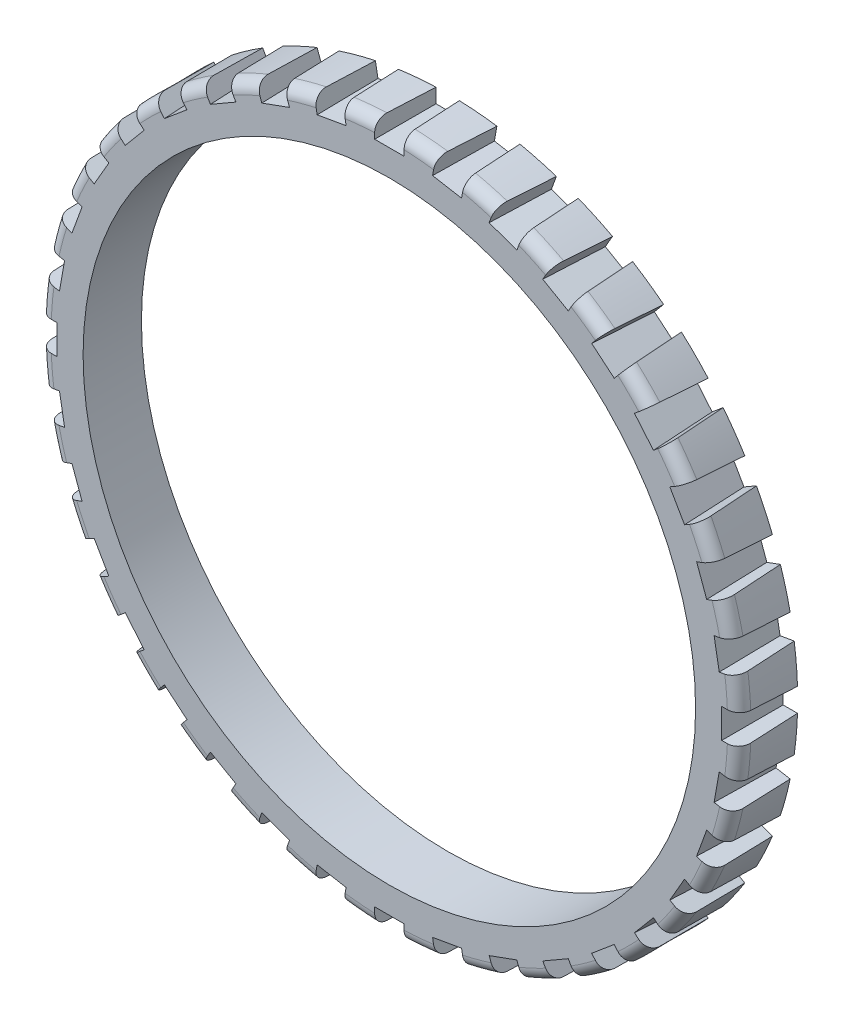
from build123d import *

# Parameters (mm, degrees)
SKETCH3_R                 = 76.2
SKETCH3_R_2               = 66.675
BOSS_EXTRUDE2_DEPTH       = 12.7
FILLET2_R                 = 2.54
CUT_EXTRUDE4_DEPTH        = 18.034
CUT_EXTRUDE4_DRAFT        = -3
CIRPATTERN1_COPY_1_DEPTH  = 18.034
CIRPATTERN1_COPY_1_DRAFT  = -3
CIRPATTERN1_COPY_2_DEPTH  = 18.034
CIRPATTERN1_COPY_2_DRAFT  = -3
CIRPATTERN1_COPY_3_DEPTH  = 18.034
CIRPATTERN1_COPY_3_DRAFT  = -3
CIRPATTERN1_COPY_4_DEPTH  = 18.034
CIRPATTERN1_COPY_4_DRAFT  = -3
CIRPATTERN1_COPY_5_DEPTH  = 18.034
CIRPATTERN1_COPY_5_DRAFT  = -3
CIRPATTERN1_COPY_6_DEPTH  = 18.034
CIRPATTERN1_COPY_6_DRAFT  = -3
CIRPATTERN1_COPY_7_DEPTH  = 18.034
CIRPATTERN1_COPY_7_DRAFT  = -3
CIRPATTERN1_COPY_8_DEPTH  = 18.034
CIRPATTERN1_COPY_8_DRAFT  = -3
CIRPATTERN1_COPY_9_DEPTH  = 18.034
CIRPATTERN1_COPY_9_DRAFT  = -3
CIRPATTERN1_COPY_10_DEPTH = 18.034
CIRPATTERN1_COPY_10_DRAFT = -3
CIRPATTERN1_COPY_11_DEPTH = 18.034
CIRPATTERN1_COPY_11_DRAFT = -3
CIRPATTERN1_COPY_12_DEPTH = 18.034
CIRPATTERN1_COPY_12_DRAFT = -3
CIRPATTERN1_COPY_13_DEPTH = 18.034
CIRPATTERN1_COPY_13_DRAFT = -3
CIRPATTERN1_COPY_14_DEPTH = 18.034
CIRPATTERN1_COPY_14_DRAFT = -3
CIRPATTERN1_COPY_15_DEPTH = 18.034
CIRPATTERN1_COPY_15_DRAFT = -3
CIRPATTERN1_COPY_16_DEPTH = 18.034
CIRPATTERN1_COPY_16_DRAFT = -3
CIRPATTERN1_COPY_17_DEPTH = 18.034
CIRPATTERN1_COPY_17_DRAFT = -3
CIRPATTERN1_COPY_18_DEPTH = 18.034
CIRPATTERN1_COPY_18_DRAFT = -3
CIRPATTERN1_COPY_19_DEPTH = 18.034
CIRPATTERN1_COPY_19_DRAFT = -3
CIRPATTERN1_COPY_20_DEPTH = 18.034
CIRPATTERN1_COPY_20_DRAFT = -3
CIRPATTERN1_COPY_21_DEPTH = 18.034
CIRPATTERN1_COPY_21_DRAFT = -3
CIRPATTERN1_COPY_22_DEPTH = 18.034
CIRPATTERN1_COPY_22_DRAFT = -3
CIRPATTERN1_COPY_23_DEPTH = 18.034
CIRPATTERN1_COPY_23_DRAFT = -3
CIRPATTERN1_COPY_24_DEPTH = 18.034
CIRPATTERN1_COPY_24_DRAFT = -3
CIRPATTERN1_COPY_25_DEPTH = 18.034
CIRPATTERN1_COPY_25_DRAFT = -3
CIRPATTERN1_COPY_26_DEPTH = 18.034
CIRPATTERN1_COPY_26_DRAFT = -3
CIRPATTERN1_COPY_27_DEPTH = 18.034
CIRPATTERN1_COPY_27_DRAFT = -3
CIRPATTERN1_COPY_28_DEPTH = 18.034
CIRPATTERN1_COPY_28_DRAFT = -3
CIRPATTERN1_COPY_29_DEPTH = 18.034
CIRPATTERN1_COPY_29_DRAFT = -3
CIRPATTERN1_COPY_30_DEPTH = 18.034
CIRPATTERN1_COPY_30_DRAFT = -3
CIRPATTERN1_COPY_31_DEPTH = 18.034
CIRPATTERN1_COPY_31_DRAFT = -3
CIRPATTERN1_COPY_32_DEPTH = 18.034
CIRPATTERN1_COPY_32_DRAFT = -3
CIRPATTERN1_COPY_33_DEPTH = 18.034
CIRPATTERN1_COPY_33_DRAFT = -3
CIRPATTERN1_COPY_34_DEPTH = 18.034
CIRPATTERN1_COPY_34_DRAFT = -3
CIRPATTERN1_COPY_35_DEPTH = 18.034
CIRPATTERN1_COPY_35_DRAFT = -3


with BuildPart() as part:
    # Sketch3 → Boss-Extrude2 (new body)
    with BuildSketch(Plane.XY.offset(12.7)):
        Circle(SKETCH3_R)
        Circle(SKETCH3_R_2, mode=Mode.SUBTRACT)
    extrude(amount=BOSS_EXTRUDE2_DEPTH)

    # Fillet2
    fillet2_edges = [part.edges().sort_by_distance(p)[0] for p in [
        (-76.2, 0, 25.4),
    ]]
    fillet(fillet2_edges, radius=FILLET2_R)


with BuildPart() as cut_extrude4_tool:
    # Sketch5 → Cut-Extrude4 (with draft: the straight prism first)
    with BuildSketch(Plane.XY.offset(12.7)):
        with BuildLine():
            Line((10.723226296, 75.441715369), (10.179246481, 72.356652535))
            Line((10.179246481, 72.356652535), (15.182069867, 71.474519792))
            Line((15.182069867, 71.474519792), (15.726049682, 74.559582626))
            ThreePointArc((15.726049682, 74.559582626), (13.231991138, 75.04235078), (10.723226296, 75.441715369))
        make_face()
    extrude(amount=CUT_EXTRUDE4_DEPTH)
    # Cut-Extrude4: the draft: its side faces are tilted about the plane it starts from
    cut_extrude4_sides = [cut_extrude4_tool.faces().sort_by_distance(p)[0] for p in [
        (10.451236389, 73.899183952, 21.717),
        (12.680658174, 71.915586164, 21.717),
        (15.454059774, 73.017051209, 21.717),
        (13.231991138, 75.04235078, 21.717),
    ]]
    draft(cut_extrude4_sides, Plane.XY.offset(12.7), CUT_EXTRUDE4_DRAFT)


with BuildPart() as part_1:
    add(part.part)

    # Cut-Extrude4: cut by cut_extrude4_tool
    add(cut_extrude4_tool.part, mode=Mode.SUBTRACT)


with BuildPart() as cirpattern1_copy_1_tool:
    # CirPattern1 copy 1 sketch → CirPattern1 copy 1 (with draft: the straight prism first)
    with BuildSketch(Plane(origin=(0, 0, 12.7), x_dir=(0.984807753012208, -0.17364817766693033, 0), z_dir=(0, 0, 1))):
        with BuildLine():
            Line((10.723226296, 75.441715369), (10.179246481, 72.356652535))
            Line((10.179246481, 72.356652535), (15.182069867, 71.474519792))
            Line((15.182069867, 71.474519792), (15.726049682, 74.559582626))
            ThreePointArc((15.726049682, 74.559582626), (13.231991138, 75.04235078), (10.723226296, 75.441715369))
        make_face()
    extrude(amount=CIRPATTERN1_COPY_1_DEPTH)
    # CirPattern1 copy 1: the draft: its side faces are tilted about the plane it starts from
    cirpattern1_copy_1_sides = [cirpattern1_copy_1_tool.faces().sort_by_distance(p)[0] for p in [
        (23.124917249, 70.961651144, 21.717),
        (24.976020966, 68.621053633, 21.717),
        (27.898555762, 69.224188815, 21.717),
        (26.061934921, 71.604577704, 21.717),
    ]]
    draft(cirpattern1_copy_1_sides, Plane(origin=(0, 0, 12.7), x_dir=(0.984807753012208, -0.17364817766693033, 0), z_dir=(0, 0, 1)), CIRPATTERN1_COPY_1_DRAFT)


with BuildPart() as part_2:
    add(part_1.part)

    # CirPattern1 copy 1: cut by cirpattern1_copy_1_tool
    add(cirpattern1_copy_1_tool.part, mode=Mode.SUBTRACT)


with BuildPart() as cirpattern1_copy_2_tool:
    # CirPattern1 copy 2 sketch → CirPattern1 copy 2 (with draft: the straight prism first)
    with BuildSketch(Plane(origin=(0, 0, 12.7), x_dir=(0.9396926207859084, -0.3420201433256687, 0), z_dir=(0, 0, 1))):
        with BuildLine():
            Line((10.723226296, 75.441715369), (10.179246481, 72.356652535))
            Line((10.179246481, 72.356652535), (15.182069867, 71.474519792))
            Line((15.182069867, 71.474519792), (15.726049682, 74.559582626))
            ThreePointArc((15.726049682, 74.559582626), (13.231991138, 75.04235078), (10.723226296, 75.441715369))
        make_face()
    extrude(amount=CIRPATTERN1_COPY_2_DEPTH)
    # CirPattern1 copy 2: the draft: its side faces are tilted about the plane it starts from
    cirpattern1_copy_2_sides = [cirpattern1_copy_2_tool.faces().sort_by_distance(p)[0] for p in [
        (35.0959592, 65.867984474, 21.717),
        (36.5125, 63.241505112, 21.717),
        (39.495368251, 63.327984474, 21.717),
        (38.1, 65.991135769, 21.717),
    ]]
    draft(cirpattern1_copy_2_sides, Plane(origin=(0, 0, 12.7), x_dir=(0.9396926207859084, -0.3420201433256687, 0), z_dir=(0, 0, 1)), CIRPATTERN1_COPY_2_DRAFT)


with BuildPart() as part_3:
    add(part_2.part)

    # CirPattern1 copy 2: cut by cirpattern1_copy_2_tool
    add(cirpattern1_copy_2_tool.part, mode=Mode.SUBTRACT)


with BuildPart() as cirpattern1_copy_3_tool:
    # CirPattern1 copy 3 sketch → CirPattern1 copy 3 (with draft: the straight prism first)
    with BuildSketch(Plane(origin=(0, 0, 12.7), x_dir=(0.8660254037844387, -0.49999999999999994, 0), z_dir=(0, 0, 1))):
        with BuildLine():
            Line((10.723226296, 75.441715369), (10.179246481, 72.356652535))
            Line((10.179246481, 72.356652535), (15.182069867, 71.474519792))
            Line((15.182069867, 71.474519792), (15.726049682, 74.559582626))
            ThreePointArc((15.726049682, 74.559582626), (13.231991138, 75.04235078), (10.723226296, 75.441715369))
        make_face()
    extrude(amount=CIRPATTERN1_COPY_3_DEPTH)
    # CirPattern1 copy 3: the draft: its side faces are tilted about the plane it starts from
    cirpattern1_copy_3_sides = [cirpattern1_copy_3_tool.faces().sort_by_distance(p)[0] for p in [
        (46.00062819, 58.772952427, 21.717),
        (46.939565197, 55.940395459, 21.717),
        (49.89213396, 55.507591369, 21.717),
        (48.980415858, 58.372586566, 21.717),
    ]]
    draft(cirpattern1_copy_3_sides, Plane(origin=(0, 0, 12.7), x_dir=(0.8660254037844387, -0.49999999999999994, 0), z_dir=(0, 0, 1)), CIRPATTERN1_COPY_3_DRAFT)


with BuildPart() as part_4:
    add(part_3.part)

    # CirPattern1 copy 3: cut by cirpattern1_copy_3_tool
    add(cirpattern1_copy_3_tool.part, mode=Mode.SUBTRACT)


with BuildPart() as cirpattern1_copy_4_tool:
    # CirPattern1 copy 4 sketch → CirPattern1 copy 4 (with draft: the straight prism first)
    with BuildSketch(Plane(origin=(0, 0, 12.7), x_dir=(0.766044443118978, -0.6427876096865393, 0), z_dir=(0, 0, 1))):
        with BuildLine():
            Line((10.723226296, 75.441715369), (10.179246481, 72.356652535))
            Line((10.179246481, 72.356652535), (15.182069867, 71.474519792))
            Line((15.182069867, 71.474519792), (15.726049682, 74.559582626))
            ThreePointArc((15.726049682, 74.559582626), (13.231991138, 75.04235078), (10.723226296, 75.441715369))
        make_face()
    extrude(amount=CIRPATTERN1_COPY_4_DEPTH)
    # CirPattern1 copy 4: the draft: its side faces are tilted about the plane it starts from
    cirpattern1_copy_4_sides = [cirpattern1_copy_4_tool.faces().sort_by_distance(p)[0] for p in [
        (55.50759137, 49.892133961, 21.717),
        (55.940395459, 46.939565198, 21.717),
        (58.772952426, 46.00062819, 21.717),
        (58.372586566, 48.980415859, 21.717),
    ]]
    draft(cirpattern1_copy_4_sides, Plane(origin=(0, 0, 12.7), x_dir=(0.766044443118978, -0.6427876096865393, 0), z_dir=(0, 0, 1)), CIRPATTERN1_COPY_4_DRAFT)


with BuildPart() as part_5:
    add(part_4.part)

    # CirPattern1 copy 4: cut by cirpattern1_copy_4_tool
    add(cirpattern1_copy_4_tool.part, mode=Mode.SUBTRACT)


with BuildPart() as cirpattern1_copy_5_tool:
    # CirPattern1 copy 5 sketch → CirPattern1 copy 5 (with draft: the straight prism first)
    with BuildSketch(Plane(origin=(0, 0, 12.7), x_dir=(0.6427876096865394, -0.766044443118978, 0), z_dir=(0, 0, 1))):
        with BuildLine():
            Line((10.723226296, 75.441715369), (10.179246481, 72.356652535))
            Line((10.179246481, 72.356652535), (15.182069867, 71.474519792))
            Line((15.182069867, 71.474519792), (15.726049682, 74.559582626))
            ThreePointArc((15.726049682, 74.559582626), (13.231991138, 75.04235078), (10.723226296, 75.441715369))
        make_face()
    extrude(amount=CIRPATTERN1_COPY_5_DEPTH)
    # CirPattern1 copy 5: the draft: its side faces are tilted about the plane it starts from
    cirpattern1_copy_5_sides = [cirpattern1_copy_5_tool.faces().sort_by_distance(p)[0] for p in [
        (63.327984474, 39.495368251, 21.717),
        (63.241505111, 36.5125, 21.717),
        (65.867984474, 35.095959199, 21.717),
        (65.991135769, 38.1, 21.717),
    ]]
    draft(cirpattern1_copy_5_sides, Plane(origin=(0, 0, 12.7), x_dir=(0.6427876096865394, -0.766044443118978, 0), z_dir=(0, 0, 1)), CIRPATTERN1_COPY_5_DRAFT)


with BuildPart() as part_6:
    add(part_5.part)

    # CirPattern1 copy 5: cut by cirpattern1_copy_5_tool
    add(cirpattern1_copy_5_tool.part, mode=Mode.SUBTRACT)


with BuildPart() as cirpattern1_copy_6_tool:
    # CirPattern1 copy 6 sketch → CirPattern1 copy 6 (with draft: the straight prism first)
    with BuildSketch(Plane(origin=(0, 0, 12.7), x_dir=(0.5000000000000001, -0.8660254037844386, 0), z_dir=(0, 0, 1))):
        with BuildLine():
            Line((10.723226296, 75.441715369), (10.179246481, 72.356652535))
            Line((10.179246481, 72.356652535), (15.182069867, 71.474519792))
            Line((15.182069867, 71.474519792), (15.726049682, 74.559582626))
            ThreePointArc((15.726049682, 74.559582626), (13.231991138, 75.04235078), (10.723226296, 75.441715369))
        make_face()
    extrude(amount=CIRPATTERN1_COPY_6_DEPTH)
    # CirPattern1 copy 6: the draft: its side faces are tilted about the plane it starts from
    cirpattern1_copy_6_sides = [cirpattern1_copy_6_tool.faces().sort_by_distance(p)[0] for p in [
        (69.224188816, 27.898555762, 21.717),
        (68.621053633, 24.976020967, 21.717),
        (70.961651143, 23.124917249, 21.717),
        (71.604577704, 26.061934922, 21.717),
    ]]
    draft(cirpattern1_copy_6_sides, Plane(origin=(0, 0, 12.7), x_dir=(0.5000000000000001, -0.8660254037844386, 0), z_dir=(0, 0, 1)), CIRPATTERN1_COPY_6_DRAFT)


with BuildPart() as part_7:
    add(part_6.part)

    # CirPattern1 copy 6: cut by cirpattern1_copy_6_tool
    add(cirpattern1_copy_6_tool.part, mode=Mode.SUBTRACT)


with BuildPart() as cirpattern1_copy_7_tool:
    # CirPattern1 copy 7 sketch → CirPattern1 copy 7 (with draft: the straight prism first)
    with BuildSketch(Plane(origin=(0, 0, 12.7), x_dir=(0.3420201433256688, -0.9396926207859083, 0), z_dir=(0, 0, 1))):
        with BuildLine():
            Line((10.723226296, 75.441715369), (10.179246481, 72.356652535))
            Line((10.179246481, 72.356652535), (15.182069867, 71.474519792))
            Line((15.182069867, 71.474519792), (15.726049682, 74.559582626))
            ThreePointArc((15.726049682, 74.559582626), (13.231991138, 75.04235078), (10.723226296, 75.441715369))
        make_face()
    extrude(amount=CIRPATTERN1_COPY_7_DEPTH)
    # CirPattern1 copy 7: the draft: its side faces are tilted about the plane it starts from
    cirpattern1_copy_7_sides = [cirpattern1_copy_7_tool.faces().sort_by_distance(p)[0] for p in [
        (73.017051209, 15.454059774, 21.717),
        (71.915586164, 12.680658174, 21.717),
        (73.899183952, 10.451236389, 21.717),
        (75.04235078, 13.231991139, 21.717),
    ]]
    draft(cirpattern1_copy_7_sides, Plane(origin=(0, 0, 12.7), x_dir=(0.3420201433256688, -0.9396926207859083, 0), z_dir=(0, 0, 1)), CIRPATTERN1_COPY_7_DRAFT)


with BuildPart() as part_8:
    add(part_7.part)

    # CirPattern1 copy 7: cut by cirpattern1_copy_7_tool
    add(cirpattern1_copy_7_tool.part, mode=Mode.SUBTRACT)


with BuildPart() as cirpattern1_copy_8_tool:
    # CirPattern1 copy 8 sketch → CirPattern1 copy 8 (with draft: the straight prism first)
    with BuildSketch(Plane(origin=(0, 0, 12.7), x_dir=(0.17364817766693041, -0.984807753012208, 0), z_dir=(0, 0, 1))):
        with BuildLine():
            Line((10.723226296, 75.441715369), (10.179246481, 72.356652535))
            Line((10.179246481, 72.356652535), (15.182069867, 71.474519792))
            Line((15.182069867, 71.474519792), (15.726049682, 74.559582626))
            ThreePointArc((15.726049682, 74.559582626), (13.231991138, 75.04235078), (10.723226296, 75.441715369))
        make_face()
    extrude(amount=CIRPATTERN1_COPY_8_DEPTH)
    # CirPattern1 copy 8: the draft: its side faces are tilted about the plane it starts from
    cirpattern1_copy_8_sides = [cirpattern1_copy_8_tool.faces().sort_by_distance(p)[0] for p in [
        (74.591327451, 2.54, 21.717),
        (73.025, 0, 21.717),
        (74.59132745, -2.54, 21.717),
        (76.2, 0, 21.717),
    ]]
    draft(cirpattern1_copy_8_sides, Plane(origin=(0, 0, 12.7), x_dir=(0.17364817766693041, -0.984807753012208, 0), z_dir=(0, 0, 1)), CIRPATTERN1_COPY_8_DRAFT)


with BuildPart() as part_9:
    add(part_8.part)

    # CirPattern1 copy 8: cut by cirpattern1_copy_8_tool
    add(cirpattern1_copy_8_tool.part, mode=Mode.SUBTRACT)


with BuildPart() as cirpattern1_copy_9_tool:
    # CirPattern1 copy 9 sketch → CirPattern1 copy 9 (with draft: the straight prism first)
    with BuildSketch(Plane(origin=(0, 0, 12.7), x_dir=(0, -1, 0), z_dir=(0, 0, 1))):
        with BuildLine():
            Line((10.723226296, 75.441715369), (10.179246481, 72.356652535))
            Line((10.179246481, 72.356652535), (15.182069867, 71.474519792))
            Line((15.182069867, 71.474519792), (15.726049682, 74.559582626))
            ThreePointArc((15.726049682, 74.559582626), (13.231991138, 75.04235078), (10.723226296, 75.441715369))
        make_face()
    extrude(amount=CIRPATTERN1_COPY_9_DEPTH)
    # CirPattern1 copy 9: the draft: its side faces are tilted about the plane it starts from
    cirpattern1_copy_9_sides = [cirpattern1_copy_9_tool.faces().sort_by_distance(p)[0] for p in [
        (73.899183952, -10.451236389, 21.717),
        (71.915586164, -12.680658174, 21.717),
        (73.017051209, -15.454059774, 21.717),
        (75.04235078, -13.231991138, 21.717),
    ]]
    draft(cirpattern1_copy_9_sides, Plane(origin=(0, 0, 12.7), x_dir=(0, -1, 0), z_dir=(0, 0, 1)), CIRPATTERN1_COPY_9_DRAFT)


with BuildPart() as part_10:
    add(part_9.part)

    # CirPattern1 copy 9: cut by cirpattern1_copy_9_tool
    add(cirpattern1_copy_9_tool.part, mode=Mode.SUBTRACT)


with BuildPart() as cirpattern1_copy_10_tool:
    # CirPattern1 copy 10 sketch → CirPattern1 copy 10 (with draft: the straight prism first)
    with BuildSketch(Plane(origin=(0, 0, 12.7), x_dir=(-0.1736481776669303, -0.984807753012208, 0), z_dir=(0, 0, 1))):
        with BuildLine():
            Line((10.723226296, 75.441715369), (10.179246481, 72.356652535))
            Line((10.179246481, 72.356652535), (15.182069867, 71.474519792))
            Line((15.182069867, 71.474519792), (15.726049682, 74.559582626))
            ThreePointArc((15.726049682, 74.559582626), (13.231991138, 75.04235078), (10.723226296, 75.441715369))
        make_face()
    extrude(amount=CIRPATTERN1_COPY_10_DEPTH)
    # CirPattern1 copy 10: the draft: its side faces are tilted about the plane it starts from
    cirpattern1_copy_10_sides = [cirpattern1_copy_10_tool.faces().sort_by_distance(p)[0] for p in [
        (70.961651144, -23.124917249, 21.717),
        (68.621053633, -24.976020966, 21.717),
        (69.224188815, -27.898555762, 21.717),
        (71.604577704, -26.061934921, 21.717),
    ]]
    draft(cirpattern1_copy_10_sides, Plane(origin=(0, 0, 12.7), x_dir=(-0.1736481776669303, -0.984807753012208, 0), z_dir=(0, 0, 1)), CIRPATTERN1_COPY_10_DRAFT)


with BuildPart() as part_11:
    add(part_10.part)

    # CirPattern1 copy 10: cut by cirpattern1_copy_10_tool
    add(cirpattern1_copy_10_tool.part, mode=Mode.SUBTRACT)


with BuildPart() as cirpattern1_copy_11_tool:
    # CirPattern1 copy 11 sketch → CirPattern1 copy 11 (with draft: the straight prism first)
    with BuildSketch(Plane(origin=(0, 0, 12.7), x_dir=(-0.3420201433256687, -0.9396926207859084, 0), z_dir=(0, 0, 1))):
        with BuildLine():
            Line((10.723226296, 75.441715369), (10.179246481, 72.356652535))
            Line((10.179246481, 72.356652535), (15.182069867, 71.474519792))
            Line((15.182069867, 71.474519792), (15.726049682, 74.559582626))
            ThreePointArc((15.726049682, 74.559582626), (13.231991138, 75.04235078), (10.723226296, 75.441715369))
        make_face()
    extrude(amount=CIRPATTERN1_COPY_11_DEPTH)
    # CirPattern1 copy 11: the draft: its side faces are tilted about the plane it starts from
    cirpattern1_copy_11_sides = [cirpattern1_copy_11_tool.faces().sort_by_distance(p)[0] for p in [
        (65.867984474, -35.0959592, 21.717),
        (63.241505112, -36.5125, 21.717),
        (63.327984474, -39.495368251, 21.717),
        (65.991135769, -38.1, 21.717),
    ]]
    draft(cirpattern1_copy_11_sides, Plane(origin=(0, 0, 12.7), x_dir=(-0.3420201433256687, -0.9396926207859084, 0), z_dir=(0, 0, 1)), CIRPATTERN1_COPY_11_DRAFT)


with BuildPart() as part_12:
    add(part_11.part)

    # CirPattern1 copy 11: cut by cirpattern1_copy_11_tool
    add(cirpattern1_copy_11_tool.part, mode=Mode.SUBTRACT)


with BuildPart() as cirpattern1_copy_12_tool:
    # CirPattern1 copy 12 sketch → CirPattern1 copy 12 (with draft: the straight prism first)
    with BuildSketch(Plane(origin=(0, 0, 12.7), x_dir=(-0.4999999999999998, -0.8660254037844387, 0), z_dir=(0, 0, 1))):
        with BuildLine():
            Line((10.723226296, 75.441715369), (10.179246481, 72.356652535))
            Line((10.179246481, 72.356652535), (15.182069867, 71.474519792))
            Line((15.182069867, 71.474519792), (15.726049682, 74.559582626))
            ThreePointArc((15.726049682, 74.559582626), (13.231991138, 75.04235078), (10.723226296, 75.441715369))
        make_face()
    extrude(amount=CIRPATTERN1_COPY_12_DEPTH)
    # CirPattern1 copy 12: the draft: its side faces are tilted about the plane it starts from
    cirpattern1_copy_12_sides = [cirpattern1_copy_12_tool.faces().sort_by_distance(p)[0] for p in [
        (58.772952427, -46.00062819, 21.717),
        (55.940395459, -46.939565197, 21.717),
        (55.507591369, -49.89213396, 21.717),
        (58.372586566, -48.980415858, 21.717),
    ]]
    draft(cirpattern1_copy_12_sides, Plane(origin=(0, 0, 12.7), x_dir=(-0.4999999999999998, -0.8660254037844387, 0), z_dir=(0, 0, 1)), CIRPATTERN1_COPY_12_DRAFT)


with BuildPart() as part_13:
    add(part_12.part)

    # CirPattern1 copy 12: cut by cirpattern1_copy_12_tool
    add(cirpattern1_copy_12_tool.part, mode=Mode.SUBTRACT)


with BuildPart() as cirpattern1_copy_13_tool:
    # CirPattern1 copy 13 sketch → CirPattern1 copy 13 (with draft: the straight prism first)
    with BuildSketch(Plane(origin=(0, 0, 12.7), x_dir=(-0.6427876096865394, -0.766044443118978, 0), z_dir=(0, 0, 1))):
        with BuildLine():
            Line((10.723226296, 75.441715369), (10.179246481, 72.356652535))
            Line((10.179246481, 72.356652535), (15.182069867, 71.474519792))
            Line((15.182069867, 71.474519792), (15.726049682, 74.559582626))
            ThreePointArc((15.726049682, 74.559582626), (13.231991138, 75.04235078), (10.723226296, 75.441715369))
        make_face()
    extrude(amount=CIRPATTERN1_COPY_13_DEPTH)
    # CirPattern1 copy 13: the draft: its side faces are tilted about the plane it starts from
    cirpattern1_copy_13_sides = [cirpattern1_copy_13_tool.faces().sort_by_distance(p)[0] for p in [
        (49.892133961, -55.50759137, 21.717),
        (46.939565198, -55.940395459, 21.717),
        (46.00062819, -58.772952426, 21.717),
        (48.980415859, -58.372586566, 21.717),
    ]]
    draft(cirpattern1_copy_13_sides, Plane(origin=(0, 0, 12.7), x_dir=(-0.6427876096865394, -0.766044443118978, 0), z_dir=(0, 0, 1)), CIRPATTERN1_COPY_13_DRAFT)


with BuildPart() as part_14:
    add(part_13.part)

    # CirPattern1 copy 13: cut by cirpattern1_copy_13_tool
    add(cirpattern1_copy_13_tool.part, mode=Mode.SUBTRACT)


with BuildPart() as cirpattern1_copy_14_tool:
    # CirPattern1 copy 14 sketch → CirPattern1 copy 14 (with draft: the straight prism first)
    with BuildSketch(Plane(origin=(0, 0, 12.7), x_dir=(-0.7660444431189779, -0.6427876096865395, 0), z_dir=(0, 0, 1))):
        with BuildLine():
            Line((10.723226296, 75.441715369), (10.179246481, 72.356652535))
            Line((10.179246481, 72.356652535), (15.182069867, 71.474519792))
            Line((15.182069867, 71.474519792), (15.726049682, 74.559582626))
            ThreePointArc((15.726049682, 74.559582626), (13.231991138, 75.04235078), (10.723226296, 75.441715369))
        make_face()
    extrude(amount=CIRPATTERN1_COPY_14_DEPTH)
    # CirPattern1 copy 14: the draft: its side faces are tilted about the plane it starts from
    cirpattern1_copy_14_sides = [cirpattern1_copy_14_tool.faces().sort_by_distance(p)[0] for p in [
        (39.495368251, -63.327984474, 21.717),
        (36.5125, -63.241505111, 21.717),
        (35.095959199, -65.867984474, 21.717),
        (38.1, -65.991135769, 21.717),
    ]]
    draft(cirpattern1_copy_14_sides, Plane(origin=(0, 0, 12.7), x_dir=(-0.7660444431189779, -0.6427876096865395, 0), z_dir=(0, 0, 1)), CIRPATTERN1_COPY_14_DRAFT)


with BuildPart() as part_15:
    add(part_14.part)

    # CirPattern1 copy 14: cut by cirpattern1_copy_14_tool
    add(cirpattern1_copy_14_tool.part, mode=Mode.SUBTRACT)


with BuildPart() as cirpattern1_copy_15_tool:
    # CirPattern1 copy 15 sketch → CirPattern1 copy 15 (with draft: the straight prism first)
    with BuildSketch(Plane(origin=(0, 0, 12.7), x_dir=(-0.8660254037844387, -0.49999999999999994, 0), z_dir=(0, 0, 1))):
        with BuildLine():
            Line((10.723226296, 75.441715369), (10.179246481, 72.356652535))
            Line((10.179246481, 72.356652535), (15.182069867, 71.474519792))
            Line((15.182069867, 71.474519792), (15.726049682, 74.559582626))
            ThreePointArc((15.726049682, 74.559582626), (13.231991138, 75.04235078), (10.723226296, 75.441715369))
        make_face()
    extrude(amount=CIRPATTERN1_COPY_15_DEPTH)
    # CirPattern1 copy 15: the draft: its side faces are tilted about the plane it starts from
    cirpattern1_copy_15_sides = [cirpattern1_copy_15_tool.faces().sort_by_distance(p)[0] for p in [
        (27.898555762, -69.224188816, 21.717),
        (24.976020967, -68.621053633, 21.717),
        (23.124917249, -70.961651143, 21.717),
        (26.061934922, -71.604577704, 21.717),
    ]]
    draft(cirpattern1_copy_15_sides, Plane(origin=(0, 0, 12.7), x_dir=(-0.8660254037844387, -0.49999999999999994, 0), z_dir=(0, 0, 1)), CIRPATTERN1_COPY_15_DRAFT)


with BuildPart() as part_16:
    add(part_15.part)

    # CirPattern1 copy 15: cut by cirpattern1_copy_15_tool
    add(cirpattern1_copy_15_tool.part, mode=Mode.SUBTRACT)


with BuildPart() as cirpattern1_copy_16_tool:
    # CirPattern1 copy 16 sketch → CirPattern1 copy 16 (with draft: the straight prism first)
    with BuildSketch(Plane(origin=(0, 0, 12.7), x_dir=(-0.9396926207859083, -0.3420201433256689, 0), z_dir=(0, 0, 1))):
        with BuildLine():
            Line((10.723226296, 75.441715369), (10.179246481, 72.356652535))
            Line((10.179246481, 72.356652535), (15.182069867, 71.474519792))
            Line((15.182069867, 71.474519792), (15.726049682, 74.559582626))
            ThreePointArc((15.726049682, 74.559582626), (13.231991138, 75.04235078), (10.723226296, 75.441715369))
        make_face()
    extrude(amount=CIRPATTERN1_COPY_16_DEPTH)
    # CirPattern1 copy 16: the draft: its side faces are tilted about the plane it starts from
    cirpattern1_copy_16_sides = [cirpattern1_copy_16_tool.faces().sort_by_distance(p)[0] for p in [
        (15.454059774, -73.017051209, 21.717),
        (12.680658174, -71.915586164, 21.717),
        (10.451236389, -73.899183952, 21.717),
        (13.231991139, -75.04235078, 21.717),
    ]]
    draft(cirpattern1_copy_16_sides, Plane(origin=(0, 0, 12.7), x_dir=(-0.9396926207859083, -0.3420201433256689, 0), z_dir=(0, 0, 1)), CIRPATTERN1_COPY_16_DRAFT)


with BuildPart() as part_17:
    add(part_16.part)

    # CirPattern1 copy 16: cut by cirpattern1_copy_16_tool
    add(cirpattern1_copy_16_tool.part, mode=Mode.SUBTRACT)


with BuildPart() as cirpattern1_copy_17_tool:
    # CirPattern1 copy 17 sketch → CirPattern1 copy 17 (with draft: the straight prism first)
    with BuildSketch(Plane(origin=(0, 0, 12.7), x_dir=(-0.984807753012208, -0.17364817766693028, 0), z_dir=(0, 0, 1))):
        with BuildLine():
            Line((10.723226296, 75.441715369), (10.179246481, 72.356652535))
            Line((10.179246481, 72.356652535), (15.182069867, 71.474519792))
            Line((15.182069867, 71.474519792), (15.726049682, 74.559582626))
            ThreePointArc((15.726049682, 74.559582626), (13.231991138, 75.04235078), (10.723226296, 75.441715369))
        make_face()
    extrude(amount=CIRPATTERN1_COPY_17_DEPTH)
    # CirPattern1 copy 17: the draft: its side faces are tilted about the plane it starts from
    cirpattern1_copy_17_sides = [cirpattern1_copy_17_tool.faces().sort_by_distance(p)[0] for p in [
        (2.54, -74.591327451, 21.717),
        (0, -73.025, 21.717),
        (-2.54, -74.59132745, 21.717),
        (0, -76.2, 21.717),
    ]]
    draft(cirpattern1_copy_17_sides, Plane(origin=(0, 0, 12.7), x_dir=(-0.984807753012208, -0.17364817766693028, 0), z_dir=(0, 0, 1)), CIRPATTERN1_COPY_17_DRAFT)


with BuildPart() as part_18:
    add(part_17.part)

    # CirPattern1 copy 17: cut by cirpattern1_copy_17_tool
    add(cirpattern1_copy_17_tool.part, mode=Mode.SUBTRACT)


with BuildPart() as cirpattern1_copy_18_tool:
    # CirPattern1 copy 18 sketch → CirPattern1 copy 18 (with draft: the straight prism first)
    with BuildSketch(Plane(origin=(0, 0, 12.7), x_dir=(-1, 0, 0), z_dir=(0, 0, 1))):
        with BuildLine():
            Line((10.723226296, 75.441715369), (10.179246481, 72.356652535))
            Line((10.179246481, 72.356652535), (15.182069867, 71.474519792))
            Line((15.182069867, 71.474519792), (15.726049682, 74.559582626))
            ThreePointArc((15.726049682, 74.559582626), (13.231991138, 75.04235078), (10.723226296, 75.441715369))
        make_face()
    extrude(amount=CIRPATTERN1_COPY_18_DEPTH)
    # CirPattern1 copy 18: the draft: its side faces are tilted about the plane it starts from
    cirpattern1_copy_18_sides = [cirpattern1_copy_18_tool.faces().sort_by_distance(p)[0] for p in [
        (-10.451236389, -73.899183952, 21.717),
        (-12.680658174, -71.915586164, 21.717),
        (-15.454059774, -73.017051209, 21.717),
        (-13.231991138, -75.04235078, 21.717),
    ]]
    draft(cirpattern1_copy_18_sides, Plane(origin=(0, 0, 12.7), x_dir=(-1, 0, 0), z_dir=(0, 0, 1)), CIRPATTERN1_COPY_18_DRAFT)


with BuildPart() as part_19:
    add(part_18.part)

    # CirPattern1 copy 18: cut by cirpattern1_copy_18_tool
    add(cirpattern1_copy_18_tool.part, mode=Mode.SUBTRACT)


with BuildPart() as cirpattern1_copy_19_tool:
    # CirPattern1 copy 19 sketch → CirPattern1 copy 19 (with draft: the straight prism first)
    with BuildSketch(Plane(origin=(0, 0, 12.7), x_dir=(-0.984807753012208, 0.17364817766693047, 0), z_dir=(0, 0, 1))):
        with BuildLine():
            Line((10.723226296, 75.441715369), (10.179246481, 72.356652535))
            Line((10.179246481, 72.356652535), (15.182069867, 71.474519792))
            Line((15.182069867, 71.474519792), (15.726049682, 74.559582626))
            ThreePointArc((15.726049682, 74.559582626), (13.231991138, 75.04235078), (10.723226296, 75.441715369))
        make_face()
    extrude(amount=CIRPATTERN1_COPY_19_DEPTH)
    # CirPattern1 copy 19: the draft: its side faces are tilted about the plane it starts from
    cirpattern1_copy_19_sides = [cirpattern1_copy_19_tool.faces().sort_by_distance(p)[0] for p in [
        (-23.124917249, -70.961651144, 21.717),
        (-24.976020966, -68.621053633, 21.717),
        (-27.898555762, -69.224188815, 21.717),
        (-26.061934921, -71.604577704, 21.717),
    ]]
    draft(cirpattern1_copy_19_sides, Plane(origin=(0, 0, 12.7), x_dir=(-0.984807753012208, 0.17364817766693047, 0), z_dir=(0, 0, 1)), CIRPATTERN1_COPY_19_DRAFT)


with BuildPart() as part_20:
    add(part_19.part)

    # CirPattern1 copy 19: cut by cirpattern1_copy_19_tool
    add(cirpattern1_copy_19_tool.part, mode=Mode.SUBTRACT)


with BuildPart() as cirpattern1_copy_20_tool:
    # CirPattern1 copy 20 sketch → CirPattern1 copy 20 (with draft: the straight prism first)
    with BuildSketch(Plane(origin=(0, 0, 12.7), x_dir=(-0.9396926207859084, 0.34202014332566866, 0), z_dir=(0, 0, 1))):
        with BuildLine():
            Line((10.723226296, 75.441715369), (10.179246481, 72.356652535))
            Line((10.179246481, 72.356652535), (15.182069867, 71.474519792))
            Line((15.182069867, 71.474519792), (15.726049682, 74.559582626))
            ThreePointArc((15.726049682, 74.559582626), (13.231991138, 75.04235078), (10.723226296, 75.441715369))
        make_face()
    extrude(amount=CIRPATTERN1_COPY_20_DEPTH)
    # CirPattern1 copy 20: the draft: its side faces are tilted about the plane it starts from
    cirpattern1_copy_20_sides = [cirpattern1_copy_20_tool.faces().sort_by_distance(p)[0] for p in [
        (-35.0959592, -65.867984474, 21.717),
        (-36.5125, -63.241505112, 21.717),
        (-39.495368251, -63.327984474, 21.717),
        (-38.1, -65.991135769, 21.717),
    ]]
    draft(cirpattern1_copy_20_sides, Plane(origin=(0, 0, 12.7), x_dir=(-0.9396926207859084, 0.34202014332566866, 0), z_dir=(0, 0, 1)), CIRPATTERN1_COPY_20_DRAFT)


with BuildPart() as part_21:
    add(part_20.part)

    # CirPattern1 copy 20: cut by cirpattern1_copy_20_tool
    add(cirpattern1_copy_20_tool.part, mode=Mode.SUBTRACT)


with BuildPart() as cirpattern1_copy_21_tool:
    # CirPattern1 copy 21 sketch → CirPattern1 copy 21 (with draft: the straight prism first)
    with BuildSketch(Plane(origin=(0, 0, 12.7), x_dir=(-0.8660254037844386, 0.5000000000000001, 0), z_dir=(0, 0, 1))):
        with BuildLine():
            Line((10.723226296, 75.441715369), (10.179246481, 72.356652535))
            Line((10.179246481, 72.356652535), (15.182069867, 71.474519792))
            Line((15.182069867, 71.474519792), (15.726049682, 74.559582626))
            ThreePointArc((15.726049682, 74.559582626), (13.231991138, 75.04235078), (10.723226296, 75.441715369))
        make_face()
    extrude(amount=CIRPATTERN1_COPY_21_DEPTH)
    # CirPattern1 copy 21: the draft: its side faces are tilted about the plane it starts from
    cirpattern1_copy_21_sides = [cirpattern1_copy_21_tool.faces().sort_by_distance(p)[0] for p in [
        (-46.00062819, -58.772952427, 21.717),
        (-46.939565197, -55.940395459, 21.717),
        (-49.89213396, -55.507591369, 21.717),
        (-48.980415858, -58.372586566, 21.717),
    ]]
    draft(cirpattern1_copy_21_sides, Plane(origin=(0, 0, 12.7), x_dir=(-0.8660254037844386, 0.5000000000000001, 0), z_dir=(0, 0, 1)), CIRPATTERN1_COPY_21_DRAFT)


with BuildPart() as part_22:
    add(part_21.part)

    # CirPattern1 copy 21: cut by cirpattern1_copy_21_tool
    add(cirpattern1_copy_21_tool.part, mode=Mode.SUBTRACT)


with BuildPart() as cirpattern1_copy_22_tool:
    # CirPattern1 copy 22 sketch → CirPattern1 copy 22 (with draft: the straight prism first)
    with BuildSketch(Plane(origin=(0, 0, 12.7), x_dir=(-0.766044443118978, 0.6427876096865393, 0), z_dir=(0, 0, 1))):
        with BuildLine():
            Line((10.723226296, 75.441715369), (10.179246481, 72.356652535))
            Line((10.179246481, 72.356652535), (15.182069867, 71.474519792))
            Line((15.182069867, 71.474519792), (15.726049682, 74.559582626))
            ThreePointArc((15.726049682, 74.559582626), (13.231991138, 75.04235078), (10.723226296, 75.441715369))
        make_face()
    extrude(amount=CIRPATTERN1_COPY_22_DEPTH)
    # CirPattern1 copy 22: the draft: its side faces are tilted about the plane it starts from
    cirpattern1_copy_22_sides = [cirpattern1_copy_22_tool.faces().sort_by_distance(p)[0] for p in [
        (-55.50759137, -49.892133961, 21.717),
        (-55.940395459, -46.939565198, 21.717),
        (-58.772952426, -46.00062819, 21.717),
        (-58.372586566, -48.980415859, 21.717),
    ]]
    draft(cirpattern1_copy_22_sides, Plane(origin=(0, 0, 12.7), x_dir=(-0.766044443118978, 0.6427876096865393, 0), z_dir=(0, 0, 1)), CIRPATTERN1_COPY_22_DRAFT)


with BuildPart() as part_23:
    add(part_22.part)

    # CirPattern1 copy 22: cut by cirpattern1_copy_22_tool
    add(cirpattern1_copy_22_tool.part, mode=Mode.SUBTRACT)


with BuildPart() as cirpattern1_copy_23_tool:
    # CirPattern1 copy 23 sketch → CirPattern1 copy 23 (with draft: the straight prism first)
    with BuildSketch(Plane(origin=(0, 0, 12.7), x_dir=(-0.6427876096865395, 0.7660444431189779, 0), z_dir=(0, 0, 1))):
        with BuildLine():
            Line((10.723226296, 75.441715369), (10.179246481, 72.356652535))
            Line((10.179246481, 72.356652535), (15.182069867, 71.474519792))
            Line((15.182069867, 71.474519792), (15.726049682, 74.559582626))
            ThreePointArc((15.726049682, 74.559582626), (13.231991138, 75.04235078), (10.723226296, 75.441715369))
        make_face()
    extrude(amount=CIRPATTERN1_COPY_23_DEPTH)
    # CirPattern1 copy 23: the draft: its side faces are tilted about the plane it starts from
    cirpattern1_copy_23_sides = [cirpattern1_copy_23_tool.faces().sort_by_distance(p)[0] for p in [
        (-63.327984474, -39.495368251, 21.717),
        (-63.241505111, -36.5125, 21.717),
        (-65.867984474, -35.095959199, 21.717),
        (-65.991135769, -38.1, 21.717),
    ]]
    draft(cirpattern1_copy_23_sides, Plane(origin=(0, 0, 12.7), x_dir=(-0.6427876096865395, 0.7660444431189779, 0), z_dir=(0, 0, 1)), CIRPATTERN1_COPY_23_DRAFT)


with BuildPart() as part_24:
    add(part_23.part)

    # CirPattern1 copy 23: cut by cirpattern1_copy_23_tool
    add(cirpattern1_copy_23_tool.part, mode=Mode.SUBTRACT)


with BuildPart() as cirpattern1_copy_24_tool:
    # CirPattern1 copy 24 sketch → CirPattern1 copy 24 (with draft: the straight prism first)
    with BuildSketch(Plane(origin=(0, 0, 12.7), x_dir=(-0.5000000000000004, 0.8660254037844384, 0), z_dir=(0, 0, 1))):
        with BuildLine():
            Line((10.723226296, 75.441715369), (10.179246481, 72.356652535))
            Line((10.179246481, 72.356652535), (15.182069867, 71.474519792))
            Line((15.182069867, 71.474519792), (15.726049682, 74.559582626))
            ThreePointArc((15.726049682, 74.559582626), (13.231991138, 75.04235078), (10.723226296, 75.441715369))
        make_face()
    extrude(amount=CIRPATTERN1_COPY_24_DEPTH)
    # CirPattern1 copy 24: the draft: its side faces are tilted about the plane it starts from
    cirpattern1_copy_24_sides = [cirpattern1_copy_24_tool.faces().sort_by_distance(p)[0] for p in [
        (-69.224188816, -27.898555762, 21.717),
        (-68.621053633, -24.976020967, 21.717),
        (-70.961651143, -23.124917249, 21.717),
        (-71.604577704, -26.061934922, 21.717),
    ]]
    draft(cirpattern1_copy_24_sides, Plane(origin=(0, 0, 12.7), x_dir=(-0.5000000000000004, 0.8660254037844384, 0), z_dir=(0, 0, 1)), CIRPATTERN1_COPY_24_DRAFT)


with BuildPart() as part_25:
    add(part_24.part)

    # CirPattern1 copy 24: cut by cirpattern1_copy_24_tool
    add(cirpattern1_copy_24_tool.part, mode=Mode.SUBTRACT)


with BuildPart() as cirpattern1_copy_25_tool:
    # CirPattern1 copy 25 sketch → CirPattern1 copy 25 (with draft: the straight prism first)
    with BuildSketch(Plane(origin=(0, 0, 12.7), x_dir=(-0.34202014332566855, 0.9396926207859084, 0), z_dir=(0, 0, 1))):
        with BuildLine():
            Line((10.723226296, 75.441715369), (10.179246481, 72.356652535))
            Line((10.179246481, 72.356652535), (15.182069867, 71.474519792))
            Line((15.182069867, 71.474519792), (15.726049682, 74.559582626))
            ThreePointArc((15.726049682, 74.559582626), (13.231991138, 75.04235078), (10.723226296, 75.441715369))
        make_face()
    extrude(amount=CIRPATTERN1_COPY_25_DEPTH)
    # CirPattern1 copy 25: the draft: its side faces are tilted about the plane it starts from
    cirpattern1_copy_25_sides = [cirpattern1_copy_25_tool.faces().sort_by_distance(p)[0] for p in [
        (-73.017051209, -15.454059774, 21.717),
        (-71.915586164, -12.680658174, 21.717),
        (-73.899183952, -10.451236389, 21.717),
        (-75.04235078, -13.231991139, 21.717),
    ]]
    draft(cirpattern1_copy_25_sides, Plane(origin=(0, 0, 12.7), x_dir=(-0.34202014332566855, 0.9396926207859084, 0), z_dir=(0, 0, 1)), CIRPATTERN1_COPY_25_DRAFT)


with BuildPart() as part_26:
    add(part_25.part)

    # CirPattern1 copy 25: cut by cirpattern1_copy_25_tool
    add(cirpattern1_copy_25_tool.part, mode=Mode.SUBTRACT)


with BuildPart() as cirpattern1_copy_26_tool:
    # CirPattern1 copy 26 sketch → CirPattern1 copy 26 (with draft: the straight prism first)
    with BuildSketch(Plane(origin=(0, 0, 12.7), x_dir=(-0.17364817766693033, 0.984807753012208, 0), z_dir=(0, 0, 1))):
        with BuildLine():
            Line((10.723226296, 75.441715369), (10.179246481, 72.356652535))
            Line((10.179246481, 72.356652535), (15.182069867, 71.474519792))
            Line((15.182069867, 71.474519792), (15.726049682, 74.559582626))
            ThreePointArc((15.726049682, 74.559582626), (13.231991138, 75.04235078), (10.723226296, 75.441715369))
        make_face()
    extrude(amount=CIRPATTERN1_COPY_26_DEPTH)
    # CirPattern1 copy 26: the draft: its side faces are tilted about the plane it starts from
    cirpattern1_copy_26_sides = [cirpattern1_copy_26_tool.faces().sort_by_distance(p)[0] for p in [
        (-74.591327451, -2.54, 21.717),
        (-73.025, 0, 21.717),
        (-74.59132745, 2.54, 21.717),
        (-76.2, 0, 21.717),
    ]]
    draft(cirpattern1_copy_26_sides, Plane(origin=(0, 0, 12.7), x_dir=(-0.17364817766693033, 0.984807753012208, 0), z_dir=(0, 0, 1)), CIRPATTERN1_COPY_26_DRAFT)


with BuildPart() as part_27:
    add(part_26.part)

    # CirPattern1 copy 26: cut by cirpattern1_copy_26_tool
    add(cirpattern1_copy_26_tool.part, mode=Mode.SUBTRACT)


with BuildPart() as cirpattern1_copy_27_tool:
    # CirPattern1 copy 27 sketch → CirPattern1 copy 27 (with draft: the straight prism first)
    with BuildSketch(Plane(origin=(0, 0, 12.7), x_dir=(0, 1, 0), z_dir=(0, 0, 1))):
        with BuildLine():
            Line((10.723226296, 75.441715369), (10.179246481, 72.356652535))
            Line((10.179246481, 72.356652535), (15.182069867, 71.474519792))
            Line((15.182069867, 71.474519792), (15.726049682, 74.559582626))
            ThreePointArc((15.726049682, 74.559582626), (13.231991138, 75.04235078), (10.723226296, 75.441715369))
        make_face()
    extrude(amount=CIRPATTERN1_COPY_27_DEPTH)
    # CirPattern1 copy 27: the draft: its side faces are tilted about the plane it starts from
    cirpattern1_copy_27_sides = [cirpattern1_copy_27_tool.faces().sort_by_distance(p)[0] for p in [
        (-73.899183952, 10.451236389, 21.717),
        (-71.915586164, 12.680658174, 21.717),
        (-73.017051209, 15.454059774, 21.717),
        (-75.04235078, 13.231991138, 21.717),
    ]]
    draft(cirpattern1_copy_27_sides, Plane(origin=(0, 0, 12.7), x_dir=(0, 1, 0), z_dir=(0, 0, 1)), CIRPATTERN1_COPY_27_DRAFT)


with BuildPart() as part_28:
    add(part_27.part)

    # CirPattern1 copy 27: cut by cirpattern1_copy_27_tool
    add(cirpattern1_copy_27_tool.part, mode=Mode.SUBTRACT)


with BuildPart() as cirpattern1_copy_28_tool:
    # CirPattern1 copy 28 sketch → CirPattern1 copy 28 (with draft: the straight prism first)
    with BuildSketch(Plane(origin=(0, 0, 12.7), x_dir=(0.17364817766692997, 0.9848077530122081, 0), z_dir=(0, 0, 1))):
        with BuildLine():
            Line((10.723226296, 75.441715369), (10.179246481, 72.356652535))
            Line((10.179246481, 72.356652535), (15.182069867, 71.474519792))
            Line((15.182069867, 71.474519792), (15.726049682, 74.559582626))
            ThreePointArc((15.726049682, 74.559582626), (13.231991138, 75.04235078), (10.723226296, 75.441715369))
        make_face()
    extrude(amount=CIRPATTERN1_COPY_28_DEPTH)
    # CirPattern1 copy 28: the draft: its side faces are tilted about the plane it starts from
    cirpattern1_copy_28_sides = [cirpattern1_copy_28_tool.faces().sort_by_distance(p)[0] for p in [
        (-70.961651144, 23.124917249, 21.717),
        (-68.621053633, 24.976020966, 21.717),
        (-69.224188815, 27.898555762, 21.717),
        (-71.604577704, 26.061934921, 21.717),
    ]]
    draft(cirpattern1_copy_28_sides, Plane(origin=(0, 0, 12.7), x_dir=(0.17364817766692997, 0.9848077530122081, 0), z_dir=(0, 0, 1)), CIRPATTERN1_COPY_28_DRAFT)


with BuildPart() as part_29:
    add(part_28.part)

    # CirPattern1 copy 28: cut by cirpattern1_copy_28_tool
    add(cirpattern1_copy_28_tool.part, mode=Mode.SUBTRACT)


with BuildPart() as cirpattern1_copy_29_tool:
    # CirPattern1 copy 29 sketch → CirPattern1 copy 29 (with draft: the straight prism first)
    with BuildSketch(Plane(origin=(0, 0, 12.7), x_dir=(0.342020143325669, 0.9396926207859083, 0), z_dir=(0, 0, 1))):
        with BuildLine():
            Line((10.723226296, 75.441715369), (10.179246481, 72.356652535))
            Line((10.179246481, 72.356652535), (15.182069867, 71.474519792))
            Line((15.182069867, 71.474519792), (15.726049682, 74.559582626))
            ThreePointArc((15.726049682, 74.559582626), (13.231991138, 75.04235078), (10.723226296, 75.441715369))
        make_face()
    extrude(amount=CIRPATTERN1_COPY_29_DEPTH)
    # CirPattern1 copy 29: the draft: its side faces are tilted about the plane it starts from
    cirpattern1_copy_29_sides = [cirpattern1_copy_29_tool.faces().sort_by_distance(p)[0] for p in [
        (-65.867984474, 35.0959592, 21.717),
        (-63.241505112, 36.5125, 21.717),
        (-63.327984474, 39.495368251, 21.717),
        (-65.991135769, 38.1, 21.717),
    ]]
    draft(cirpattern1_copy_29_sides, Plane(origin=(0, 0, 12.7), x_dir=(0.342020143325669, 0.9396926207859083, 0), z_dir=(0, 0, 1)), CIRPATTERN1_COPY_29_DRAFT)


with BuildPart() as part_30:
    add(part_29.part)

    # CirPattern1 copy 29: cut by cirpattern1_copy_29_tool
    add(cirpattern1_copy_29_tool.part, mode=Mode.SUBTRACT)


with BuildPart() as cirpattern1_copy_30_tool:
    # CirPattern1 copy 30 sketch → CirPattern1 copy 30 (with draft: the straight prism first)
    with BuildSketch(Plane(origin=(0, 0, 12.7), x_dir=(0.5000000000000001, 0.8660254037844386, 0), z_dir=(0, 0, 1))):
        with BuildLine():
            Line((10.723226296, 75.441715369), (10.179246481, 72.356652535))
            Line((10.179246481, 72.356652535), (15.182069867, 71.474519792))
            Line((15.182069867, 71.474519792), (15.726049682, 74.559582626))
            ThreePointArc((15.726049682, 74.559582626), (13.231991138, 75.04235078), (10.723226296, 75.441715369))
        make_face()
    extrude(amount=CIRPATTERN1_COPY_30_DEPTH)
    # CirPattern1 copy 30: the draft: its side faces are tilted about the plane it starts from
    cirpattern1_copy_30_sides = [cirpattern1_copy_30_tool.faces().sort_by_distance(p)[0] for p in [
        (-58.772952427, 46.00062819, 21.717),
        (-55.940395459, 46.939565197, 21.717),
        (-55.507591369, 49.89213396, 21.717),
        (-58.372586566, 48.980415858, 21.717),
    ]]
    draft(cirpattern1_copy_30_sides, Plane(origin=(0, 0, 12.7), x_dir=(0.5000000000000001, 0.8660254037844386, 0), z_dir=(0, 0, 1)), CIRPATTERN1_COPY_30_DRAFT)


with BuildPart() as part_31:
    add(part_30.part)

    # CirPattern1 copy 30: cut by cirpattern1_copy_30_tool
    add(cirpattern1_copy_30_tool.part, mode=Mode.SUBTRACT)


with BuildPart() as cirpattern1_copy_31_tool:
    # CirPattern1 copy 31 sketch → CirPattern1 copy 31 (with draft: the straight prism first)
    with BuildSketch(Plane(origin=(0, 0, 12.7), x_dir=(0.6427876096865393, 0.7660444431189781, 0), z_dir=(0, 0, 1))):
        with BuildLine():
            Line((10.723226296, 75.441715369), (10.179246481, 72.356652535))
            Line((10.179246481, 72.356652535), (15.182069867, 71.474519792))
            Line((15.182069867, 71.474519792), (15.726049682, 74.559582626))
            ThreePointArc((15.726049682, 74.559582626), (13.231991138, 75.04235078), (10.723226296, 75.441715369))
        make_face()
    extrude(amount=CIRPATTERN1_COPY_31_DEPTH)
    # CirPattern1 copy 31: the draft: its side faces are tilted about the plane it starts from
    cirpattern1_copy_31_sides = [cirpattern1_copy_31_tool.faces().sort_by_distance(p)[0] for p in [
        (-49.892133961, 55.50759137, 21.717),
        (-46.939565198, 55.940395459, 21.717),
        (-46.00062819, 58.772952426, 21.717),
        (-48.980415859, 58.372586566, 21.717),
    ]]
    draft(cirpattern1_copy_31_sides, Plane(origin=(0, 0, 12.7), x_dir=(0.6427876096865393, 0.7660444431189781, 0), z_dir=(0, 0, 1)), CIRPATTERN1_COPY_31_DRAFT)


with BuildPart() as part_32:
    add(part_31.part)

    # CirPattern1 copy 31: cut by cirpattern1_copy_31_tool
    add(cirpattern1_copy_31_tool.part, mode=Mode.SUBTRACT)


with BuildPart() as cirpattern1_copy_32_tool:
    # CirPattern1 copy 32 sketch → CirPattern1 copy 32 (with draft: the straight prism first)
    with BuildSketch(Plane(origin=(0, 0, 12.7), x_dir=(0.7660444431189778, 0.6427876096865396, 0), z_dir=(0, 0, 1))):
        with BuildLine():
            Line((10.723226296, 75.441715369), (10.179246481, 72.356652535))
            Line((10.179246481, 72.356652535), (15.182069867, 71.474519792))
            Line((15.182069867, 71.474519792), (15.726049682, 74.559582626))
            ThreePointArc((15.726049682, 74.559582626), (13.231991138, 75.04235078), (10.723226296, 75.441715369))
        make_face()
    extrude(amount=CIRPATTERN1_COPY_32_DEPTH)
    # CirPattern1 copy 32: the draft: its side faces are tilted about the plane it starts from
    cirpattern1_copy_32_sides = [cirpattern1_copy_32_tool.faces().sort_by_distance(p)[0] for p in [
        (-39.495368251, 63.327984474, 21.717),
        (-36.5125, 63.241505111, 21.717),
        (-35.095959199, 65.867984474, 21.717),
        (-38.1, 65.991135769, 21.717),
    ]]
    draft(cirpattern1_copy_32_sides, Plane(origin=(0, 0, 12.7), x_dir=(0.7660444431189778, 0.6427876096865396, 0), z_dir=(0, 0, 1)), CIRPATTERN1_COPY_32_DRAFT)


with BuildPart() as part_33:
    add(part_32.part)

    # CirPattern1 copy 32: cut by cirpattern1_copy_32_tool
    add(cirpattern1_copy_32_tool.part, mode=Mode.SUBTRACT)


with BuildPart() as cirpattern1_copy_33_tool:
    # CirPattern1 copy 33 sketch → CirPattern1 copy 33 (with draft: the straight prism first)
    with BuildSketch(Plane(origin=(0, 0, 12.7), x_dir=(0.8660254037844384, 0.5000000000000004, 0), z_dir=(0, 0, 1))):
        with BuildLine():
            Line((10.723226296, 75.441715369), (10.179246481, 72.356652535))
            Line((10.179246481, 72.356652535), (15.182069867, 71.474519792))
            Line((15.182069867, 71.474519792), (15.726049682, 74.559582626))
            ThreePointArc((15.726049682, 74.559582626), (13.231991138, 75.04235078), (10.723226296, 75.441715369))
        make_face()
    extrude(amount=CIRPATTERN1_COPY_33_DEPTH)
    # CirPattern1 copy 33: the draft: its side faces are tilted about the plane it starts from
    cirpattern1_copy_33_sides = [cirpattern1_copy_33_tool.faces().sort_by_distance(p)[0] for p in [
        (-27.898555762, 69.224188816, 21.717),
        (-24.976020967, 68.621053633, 21.717),
        (-23.124917249, 70.961651143, 21.717),
        (-26.061934922, 71.604577704, 21.717),
    ]]
    draft(cirpattern1_copy_33_sides, Plane(origin=(0, 0, 12.7), x_dir=(0.8660254037844384, 0.5000000000000004, 0), z_dir=(0, 0, 1)), CIRPATTERN1_COPY_33_DRAFT)


with BuildPart() as part_34:
    add(part_33.part)

    # CirPattern1 copy 33: cut by cirpattern1_copy_33_tool
    add(cirpattern1_copy_33_tool.part, mode=Mode.SUBTRACT)


with BuildPart() as cirpattern1_copy_34_tool:
    # CirPattern1 copy 34 sketch → CirPattern1 copy 34 (with draft: the straight prism first)
    with BuildSketch(Plane(origin=(0, 0, 12.7), x_dir=(0.9396926207859084, 0.3420201433256686, 0), z_dir=(0, 0, 1))):
        with BuildLine():
            Line((10.723226296, 75.441715369), (10.179246481, 72.356652535))
            Line((10.179246481, 72.356652535), (15.182069867, 71.474519792))
            Line((15.182069867, 71.474519792), (15.726049682, 74.559582626))
            ThreePointArc((15.726049682, 74.559582626), (13.231991138, 75.04235078), (10.723226296, 75.441715369))
        make_face()
    extrude(amount=CIRPATTERN1_COPY_34_DEPTH)
    # CirPattern1 copy 34: the draft: its side faces are tilted about the plane it starts from
    cirpattern1_copy_34_sides = [cirpattern1_copy_34_tool.faces().sort_by_distance(p)[0] for p in [
        (-15.454059774, 73.017051209, 21.717),
        (-12.680658174, 71.915586164, 21.717),
        (-10.451236389, 73.899183952, 21.717),
        (-13.231991139, 75.04235078, 21.717),
    ]]
    draft(cirpattern1_copy_34_sides, Plane(origin=(0, 0, 12.7), x_dir=(0.9396926207859084, 0.3420201433256686, 0), z_dir=(0, 0, 1)), CIRPATTERN1_COPY_34_DRAFT)


with BuildPart() as part_35:
    add(part_34.part)

    # CirPattern1 copy 34: cut by cirpattern1_copy_34_tool
    add(cirpattern1_copy_34_tool.part, mode=Mode.SUBTRACT)


with BuildPart() as cirpattern1_copy_35_tool:
    # CirPattern1 copy 35 sketch → CirPattern1 copy 35 (with draft: the straight prism first)
    with BuildSketch(Plane(origin=(0, 0, 12.7), x_dir=(0.984807753012208, 0.1736481776669304, 0), z_dir=(0, 0, 1))):
        with BuildLine():
            Line((10.723226296, 75.441715369), (10.179246481, 72.356652535))
            Line((10.179246481, 72.356652535), (15.182069867, 71.474519792))
            Line((15.182069867, 71.474519792), (15.726049682, 74.559582626))
            ThreePointArc((15.726049682, 74.559582626), (13.231991138, 75.04235078), (10.723226296, 75.441715369))
        make_face()
    extrude(amount=CIRPATTERN1_COPY_35_DEPTH)
    # CirPattern1 copy 35: the draft: its side faces are tilted about the plane it starts from
    cirpattern1_copy_35_sides = [cirpattern1_copy_35_tool.faces().sort_by_distance(p)[0] for p in [
        (-2.54, 74.591327451, 21.717),
        (0, 73.025, 21.717),
        (2.54, 74.59132745, 21.717),
        (0, 76.2, 21.717),
    ]]
    draft(cirpattern1_copy_35_sides, Plane(origin=(0, 0, 12.7), x_dir=(0.984807753012208, 0.1736481776669304, 0), z_dir=(0, 0, 1)), CIRPATTERN1_COPY_35_DRAFT)


with BuildPart() as part_36:
    add(part_35.part)

    # CirPattern1 copy 35: cut by cirpattern1_copy_35_tool
    add(cirpattern1_copy_35_tool.part, mode=Mode.SUBTRACT)


solid = part_36.part
